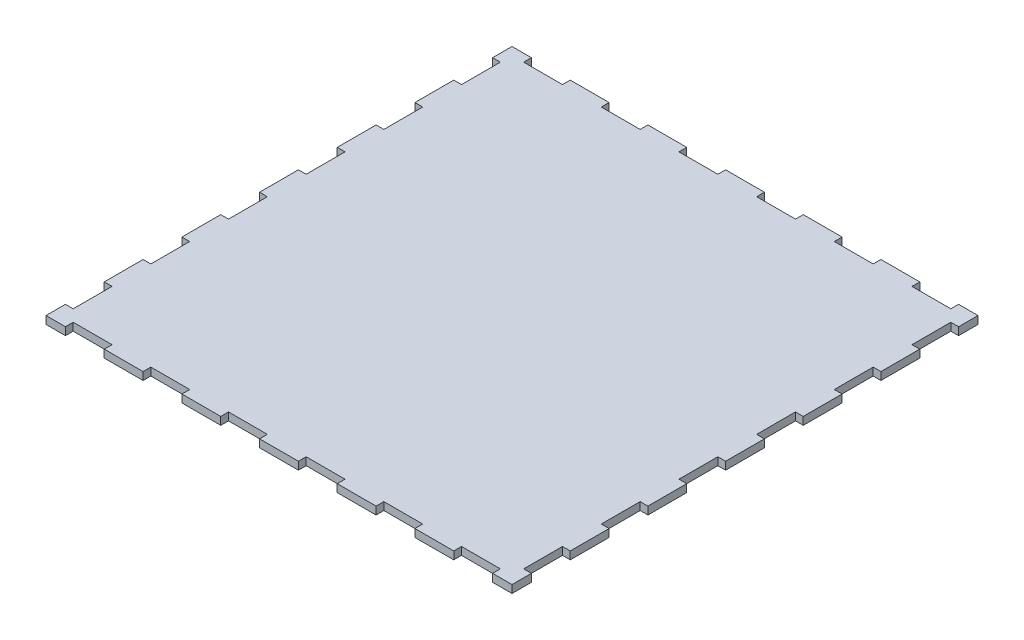
from build123d import *

# Parameters (mm, degrees)
BOSS_EXTRUDE1_DEPTH = 2.54


with BuildPart() as part:
    # Sketch1 → Boss-Extrude1 (new body, symmetric)
    with BuildSketch(Plane(origin=(0, 0, 0), x_dir=(1, 0, 0), z_dir=(0, 1, 0))):
        Polygon((12.7, 152.4), (-12.7, 152.4), (-12.7, 147.32), (-38.1, 147.32), (-38.1, 152.4), (-63.5, 152.4), (-63.5, 147.32), (-88.9, 147.32), (-88.9, 152.4), (-114.3, 152.4), (-114.3, 147.32), (-139.7, 147.32), (-139.7, 152.4), (-152.4, 152.4), (-152.4, 139.7), (-147.32, 139.7), (-147.32, 114.3), (-152.4, 114.3), (-152.4, 88.9), (-147.32, 88.9), (-147.32, 63.5), (-152.4, 63.5), (-152.4, 38.1), (-147.32, 38.1), (-147.32, 12.7), (-152.4, 12.7), (-152.4, -12.7), (-147.32, -12.7), (-147.32, -38.1), (-152.4, -38.1), (-152.4, -63.5), (-147.32, -63.5), (-147.32, -88.9), (-152.4, -88.9), (-152.4, -114.3), (-147.32, -114.3), (-147.32, -139.7), (-152.4, -139.7), (-152.4, -152.4), (-139.7, -152.4), (-139.7, -147.32), (-114.3, -147.32), (-114.3, -152.4), (-88.9, -152.4), (-88.9, -147.32), (-63.5, -147.32), (-63.5, -152.4), (-38.1, -152.4), (-38.1, -147.32), (-12.7, -147.32), (-12.7, -152.4), (12.7, -152.4), (12.7, -147.32), (38.1, -147.32), (38.1, -152.4), (63.5, -152.4), (63.5, -147.32), (88.9, -147.32), (88.9, -152.4), (114.3, -152.4), (114.3, -147.32), (139.7, -147.32), (139.7, -152.4), (152.4, -152.4), (152.4, -139.7), (147.32, -139.7), (147.32, -114.3), (152.4, -114.3), (152.4, -88.9), (147.32, -88.9), (147.32, -63.5), (152.4, -63.5), (152.4, -38.1), (147.32, -38.1), (147.32, -12.7), (152.4, -12.7), (152.4, 12.7), (147.32, 12.7), (147.32, 38.1), (152.4, 38.1), (152.4, 63.5), (147.32, 63.5), (147.32, 88.9), (152.4, 88.9), (152.4, 114.3), (147.32, 114.3), (147.32, 139.7), (152.4, 139.7), (152.4, 152.4), (139.7, 152.4), (139.7, 147.32), (114.3, 147.32), (114.3, 152.4), (88.9, 152.4), (88.9, 147.32), (63.5, 147.32), (63.5, 152.4), (38.1, 152.4), (38.1, 147.32), (12.7, 147.32), align=None)
    extrude(amount=BOSS_EXTRUDE1_DEPTH, both=True)


solid = part.part
